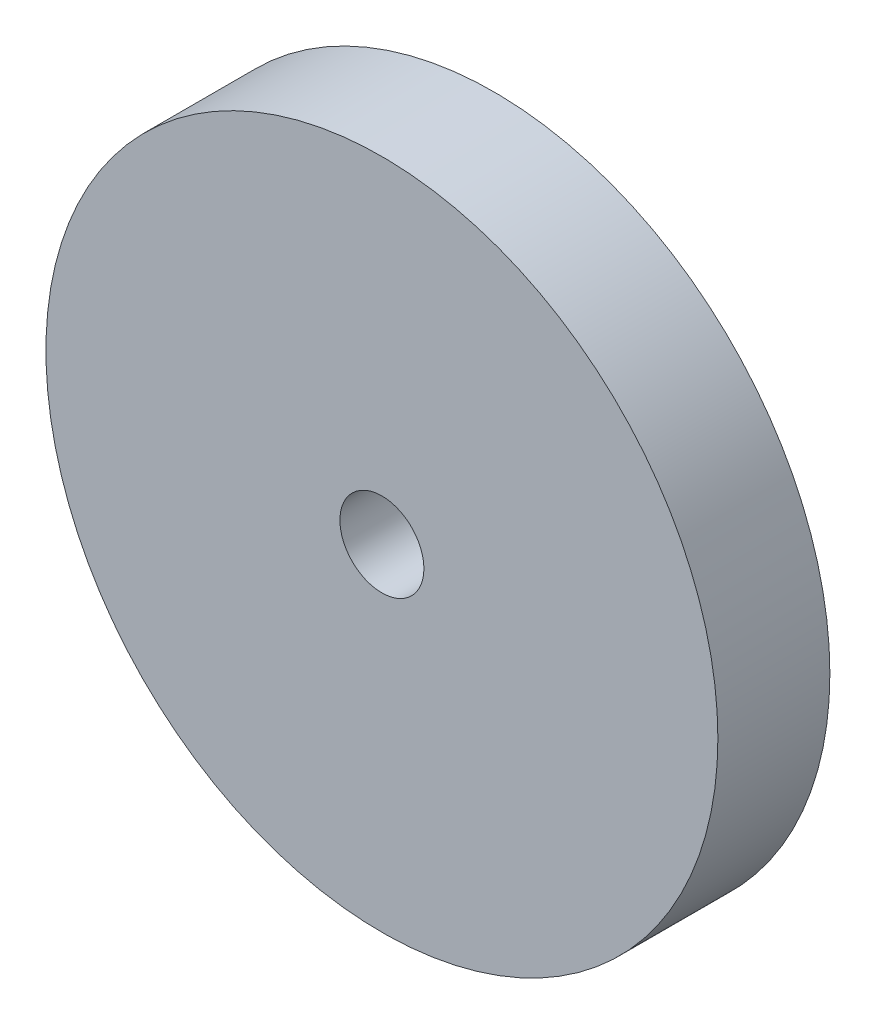
from build123d import *

# Parameters (mm, degrees)
SKETCH1_R           = 76.2
SKETCH1_R_2         = 9.525
BOSS_EXTRUDE1_DEPTH = 25.4
SKETCH2_R           = 31.75
BOSS_EXTRUDE2_DEPTH = 22.225


with BuildPart() as part:
    # Sketch1 → Boss-Extrude1 (new body)
    with BuildSketch(Plane.XY):
        Circle(SKETCH1_R)
        Circle(SKETCH1_R_2, mode=Mode.SUBTRACT)
    extrude(amount=BOSS_EXTRUDE1_DEPTH)

    # Sketch2 → Boss-Extrude2 (add)
    with BuildSketch(Plane.XY):
        Circle(SKETCH2_R)
    extrude(amount=-BOSS_EXTRUDE2_DEPTH)


solid = part.part
